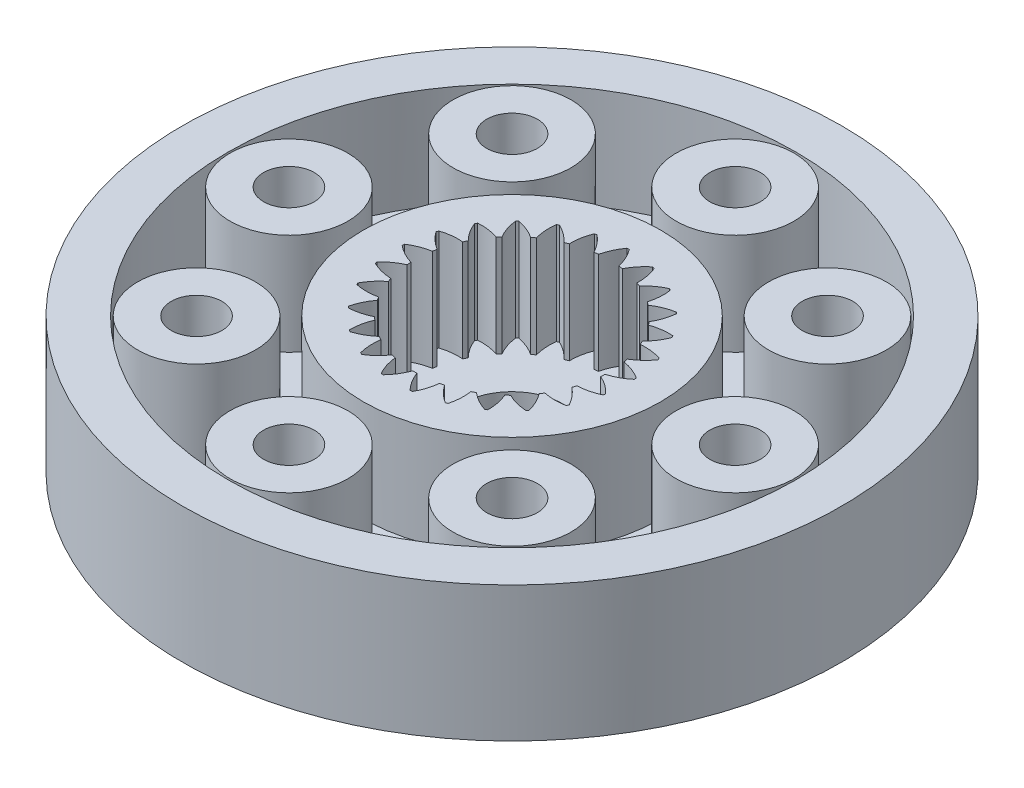
from build123d import *

# Parameters (mm, degrees)
SKETCH_1_R          = 9.75
EXTRUDE_1_DEPTH     = 3
SKETCH_2_R          = 9.75
EXTRUDE_2_DEPTH     = 1
SKETCH_4_R          = 1.5
CUT_EXTRUDE_4_DEPTH = 1
SKETCH_5_R          = 8.4
SKETCH_5_R_2        = 4.4
CUT_EXTRUDE_5_DEPTH = 10
SKETCH_6_R          = 1.744482362
SKETCH_6_R_2        = 0.75
EXTRUDE_3_DEPTH     = 3
SKETCH_7_R          = 0.75
SKETCH_7_R_2        = 1.5
CUT_EXTRUDE_6_DEPTH = 3


with BuildPart() as part:
    # 草图1 → 凸台-拉伸1 (new body)
    with BuildSketch(Plane(origin=(0, 0, 0), x_dir=(1, 0, 0), z_dir=(0, 1, 0))):
        with Locations((0.394660743, -0.591991115)):
            Circle(SKETCH_1_R)
        with BuildLine():
            ThreePointArc((-0.026116093, 2.25205035), (-0.201664975, 2.520045602), (-0.42818362, 2.746602811))
            ThreePointArc((-0.42818362, 2.746602811), (-0.460459434, 2.738482084), (-0.492655135, 2.73004934))
            ThreePointArc((-0.492655135, 2.73004934), (-0.582010169, 2.422389555), (-0.606737129, 2.102972206))
            ThreePointArc((-0.606737129, 2.102972206), (-0.663697346, 2.081116282), (-0.720180966, 2.058056613))
            ThreePointArc((-0.720180966, 2.058056613), (-0.956862366, 2.27397507), (-1.232606998, 2.437081672))
            ThreePointArc((-1.232606998, 2.437081672), (-1.261849265, 2.421189404), (-1.290936341, 2.405014844))
            ThreePointArc((-1.290936341, 2.405014844), (-1.300972245, 2.084799064), (-1.245486498, 1.769267453))
            ThreePointArc((-1.245486498, 1.769267453), (-1.295221857, 1.733932744), (-1.344196234, 1.697550632))
            ThreePointArc((-1.344196234, 1.697550632), (-1.62713859, 1.847825343), (-1.934783159, 1.937232749))
            ThreePointArc((-1.934783159, 1.937232749), (-1.95915448, 1.91456751), (-1.983305283, 1.891667442))
            ThreePointArc((-1.983305283, 1.891667442), (-1.913391464, 1.579016002), (-1.781179383, 1.287196141))
            ThreePointArc((-1.781179383, 1.287196141), (-1.82056483, 1.240602855), (-1.858952723, 1.193184322))
            ThreePointArc((-1.858952723, 1.193184322), (-2.170377725, 1.268372974), (-2.490591793, 1.278463389))
            ThreePointArc((-2.490591793, 1.278463389), (-2.508560828, 1.250449319), (-2.526257873, 1.222262639))
            ThreePointArc((-2.526257873, 1.222262639), (-2.380787274, 0.936820578), (-2.180156231, 0.687048582))
            ThreePointArc((-2.180156231, 0.687048582), (-2.206717032, 0.632124348), (-2.23210639, 0.576648875))
            ThreePointArc((-2.23210639, 0.576648875), (-2.552446061, 0.572027088), (-2.865109398, 0.502166494))
            ThreePointArc((-2.865109398, 0.502166494), (-2.875547088, 0.47056382), (-2.885678405, 0.4388616))
            ThreePointArc((-2.885678405, 0.4388616), (-2.673791479, 0.198564293), (-2.417347859, 0.006534255))
            ThreePointArc((-2.417347859, 0.006534255), (-2.429415102, -0.053269836), (-2.440210618, -0.113316522))
            ThreePointArc((-2.440210618, -0.113316522), (-2.749336837, -0.197458343), (-3.034803657, -0.342880348))
            ThreePointArc((-3.034803657, -0.342880348), (-3.037054162, -0.376085914), (-3.038983164, -0.409311707))
            ThreePointArc((-3.038983164, -0.409311707), (-2.773993545, -0.589365496), (-2.477850645, -0.711587622))
            ThreePointArc((-2.477850645, -0.711587622), (-2.474666101, -0.772513859), (-2.470189451, -0.833358803))
            ThreePointArc((-2.470189451, -0.833358803), (-2.748678682, -0.991733719), (-2.989012055, -1.203579736))
            ThreePointArc((-2.989012055, -1.203579736), (-2.982933968, -1.236301765), (-2.976539448, -1.268963432))
            ThreePointArc((-2.976539448, -1.268963432), (-2.675097409, -1.377460262), (-2.357862976, -1.422194811))
            ThreePointArc((-2.357862976, -1.422194811), (-2.339626741, -1.480414974), (-2.320159211, -1.538235065))
            ThreePointArc((-2.320159211, -1.538235065), (-2.550512951, -1.760891797), (-2.730611847, -2.025850761))
            ThreePointArc((-2.730611847, -2.025850761), (-2.716587076, -2.056033209), (-2.702270826, -2.086078497))
            ThreePointArc((-2.702270826, -2.086078497), (-2.383317078, -2.116201113), (-2.064924118, -2.080637248))
            ThreePointArc((-2.064924118, -2.080637248), (-2.032782042, -2.132493151), (-1.999546849, -2.18365534))
            ThreePointArc((-1.999546849, -2.18365534), (-2.167291125, -2.456603546), (-2.275839268, -2.758027112))
            ThreePointArc((-2.275839268, -2.758027112), (-2.254749042, -2.783773504), (-2.233410603, -2.809314557))
            ThreePointArc((-2.233410603, -2.809314557), (-1.916986184, -2.759170244), (-1.617440498, -2.645542574))
            ThreePointArc((-1.617440498, -2.645542574), (-1.573412186, -2.687775919), (-1.528497619, -2.729065497))
            ThreePointArc((-1.528497619, -2.729065497), (-1.623092441, -3.035154839), (-1.653269352, -3.354103454))
            ThreePointArc((-1.653269352, -3.354103454), (-1.626438847, -3.37379605), (-1.599418993, -3.393228031))
            ThreePointArc((-1.599418993, -3.393228031), (-1.305406012, -3.26596754), (-1.043529157, -3.081415709))
            ThreePointArc((-1.043529157, -3.081415709), (-0.99038107, -3.11137282), (-0.936609275, -3.140195412))
            ThreePointArc((-0.936609275, -3.140195412), (-0.952110903, -3.460193169), (-0.902020456, -3.77662612))
            ThreePointArc((-0.902020456, -3.77662612), (-0.871135531, -3.789027562), (-0.840132018, -3.801129486))
            ThreePointArc((-0.840132018, -3.801129486), (-0.587004393, -3.604749063), (-0.379251055, -3.360869142))
            ThreePointArc((-0.379251055, -3.360869142), (-0.320322682, -3.376667703), (-0.261072341, -3.391212279))
            ThreePointArc((-0.261072341, -3.391212279), (-0.19650675, -3.705011816), (-0.069296312, -3.999046457))
            ThreePointArc((-0.069296312, -3.999046457), (-0.03629758, -4.003377516), (-0.003258474, -4.007388976))
            ThreePointArc((-0.003258474, -4.007388976), (0.193078856, -3.754227924), (0.333654771, -3.466343785))
            ThreePointArc((0.333654771, -3.466343785), (0.394660743, -3.466991115), (0.455666715, -3.466343785))
            ThreePointArc((0.455666715, -3.466343785), (0.596242631, -3.754227924), (0.792579961, -4.007388976))
            ThreePointArc((0.792579961, -4.007388976), (0.825619067, -4.003377516), (0.858617799, -3.999046457))
            ThreePointArc((0.858617799, -3.999046457), (0.985828237, -3.705011816), (1.050393827, -3.391212279))
            ThreePointArc((1.050393827, -3.391212279), (1.109644169, -3.376667703), (1.168572542, -3.360869142))
            ThreePointArc((1.168572542, -3.360869142), (1.37632588, -3.604749063), (1.629453505, -3.801129486))
            ThreePointArc((1.629453505, -3.801129486), (1.660457018, -3.789027562), (1.691341943, -3.77662612))
            ThreePointArc((1.691341943, -3.77662612), (1.74143239, -3.460193169), (1.725930762, -3.140195412))
            ThreePointArc((1.725930762, -3.140195412), (1.779702556, -3.11137282), (1.832850644, -3.081415709))
            ThreePointArc((1.832850644, -3.081415709), (2.094727499, -3.26596754), (2.388740479, -3.393228031))
            ThreePointArc((2.388740479, -3.393228031), (2.415760333, -3.37379605), (2.442590839, -3.354103454))
            ThreePointArc((2.442590839, -3.354103454), (2.412413927, -3.035154839), (2.317819105, -2.729065497))
            ThreePointArc((2.317819105, -2.729065497), (2.362733673, -2.687775919), (2.406761985, -2.645542574))
            ThreePointArc((2.406761985, -2.645542574), (2.706307671, -2.759170244), (3.02273209, -2.809314557))
            ThreePointArc((3.02273209, -2.809314557), (3.044070529, -2.783773504), (3.065160755, -2.758027112))
            ThreePointArc((3.065160755, -2.758027112), (2.956612612, -2.456603546), (2.788868336, -2.18365534))
            ThreePointArc((2.788868336, -2.18365534), (2.822103529, -2.132493151), (2.854245605, -2.080637248))
            ThreePointArc((2.854245605, -2.080637248), (3.172638565, -2.116201113), (3.491592313, -2.086078497))
            ThreePointArc((3.491592313, -2.086078497), (3.505908563, -2.056033209), (3.519933334, -2.025850761))
            ThreePointArc((3.519933334, -2.025850761), (3.339834438, -1.760891797), (3.109480698, -1.538235065))
            ThreePointArc((3.109480698, -1.538235065), (3.128948228, -1.480414974), (3.147184462, -1.422194811))
            ThreePointArc((3.147184462, -1.422194811), (3.464418895, -1.377460262), (3.765860935, -1.268963432))
            ThreePointArc((3.765860935, -1.268963432), (3.772255455, -1.236301765), (3.778333542, -1.203579736))
            ThreePointArc((3.778333542, -1.203579736), (3.538000169, -0.991733719), (3.259510938, -0.833358803))
            ThreePointArc((3.259510938, -0.833358803), (3.263987588, -0.772513859), (3.267172132, -0.711587622))
            ThreePointArc((3.267172132, -0.711587622), (3.563315032, -0.589365496), (3.828304651, -0.409311707))
            ThreePointArc((3.828304651, -0.409311707), (3.826375649, -0.376085914), (3.824125144, -0.342880348))
            ThreePointArc((3.824125144, -0.342880348), (3.538658323, -0.197458343), (3.229532104, -0.113316522))
            ThreePointArc((3.229532104, -0.113316522), (3.218736589, -0.053269836), (3.206669346, 0.006534255))
            ThreePointArc((3.206669346, 0.006534255), (3.463112965, 0.198564293), (3.674999892, 0.4388616))
            ThreePointArc((3.674999892, 0.4388616), (3.664868575, 0.47056382), (3.654430885, 0.502166494))
            ThreePointArc((3.654430885, 0.502166494), (3.341767547, 0.572027088), (3.021427877, 0.576648875))
            ThreePointArc((3.021427877, 0.576648875), (2.996038519, 0.632124348), (2.969477718, 0.687048582))
            ThreePointArc((2.969477718, 0.687048582), (3.170108761, 0.936820578), (3.31557936, 1.222262639))
            ThreePointArc((3.31557936, 1.222262639), (3.297882315, 1.250449319), (3.279913279, 1.278463389))
            ThreePointArc((3.279913279, 1.278463389), (2.959699212, 1.268372974), (2.64827421, 1.193184322))
            ThreePointArc((2.64827421, 1.193184322), (2.609886316, 1.240602855), (2.57050087, 1.287196141))
            ThreePointArc((2.57050087, 1.287196141), (2.702712951, 1.579016002), (2.772626769, 1.891667442))
            ThreePointArc((2.772626769, 1.891667442), (2.748475967, 1.91456751), (2.724104646, 1.937232749))
            ThreePointArc((2.724104646, 1.937232749), (2.416460076, 1.847825343), (2.133517721, 1.697550632))
            ThreePointArc((2.133517721, 1.697550632), (2.084543344, 1.733932744), (2.034807985, 1.769267453))
            ThreePointArc((2.034807985, 1.769267453), (2.090293731, 2.084799064), (2.080257828, 2.405014844))
            ThreePointArc((2.080257828, 2.405014844), (2.051170752, 2.421189404), (2.021928485, 2.437081672))
            ThreePointArc((2.021928485, 2.437081672), (1.746183853, 2.27397507), (1.509502453, 2.058056613))
            ThreePointArc((1.509502453, 2.058056613), (1.453018832, 2.081116282), (1.396058616, 2.102972206))
            ThreePointArc((1.396058616, 2.102972206), (1.371331655, 2.422389555), (1.281976622, 2.73004934))
            ThreePointArc((1.281976622, 2.73004934), (1.24978092, 2.738482084), (1.217505107, 2.746602811))
            ThreePointArc((1.217505107, 2.746602811), (0.990986462, 2.520045602), (0.81543758, 2.25205035))
            ThreePointArc((0.81543758, 2.25205035), (0.75499379, 2.260338651), (0.694387736, 2.267342501))
            ThreePointArc((0.694387736, 2.267342501), (0.591001754, 2.570575422), (0.427942096, 2.846347815))
            ThreePointArc((0.427942096, 2.846347815), (0.394660743, 2.846508885), (0.361379391, 2.846347815))
            ThreePointArc((0.361379391, 2.846347815), (0.198319733, 2.570575422), (0.094933751, 2.267342501))
            ThreePointArc((0.094933751, 2.267342501), (0.034327697, 2.260338651), (-0.026116093, 2.25205035))
        make_face(mode=Mode.SUBTRACT)
    extrude(amount=EXTRUDE_1_DEPTH)

    # 草图2 → 凸台-拉伸2 (add)
    with BuildSketch(Plane(origin=(0, 0, 0), x_dir=(-1, 0, 0), z_dir=(0, -1, 0))):
        with Locations((-0.394660743, -0.591991115)):
            Circle(SKETCH_2_R)
    extrude(amount=EXTRUDE_2_DEPTH)

    # 草图4 → 切除-拉伸4 (cut)
    with BuildSketch(Plane(origin=(0, 0, 0), x_dir=(1, 0, 0), z_dir=(0, 1, 0))):
        with Locations((0.394660743, -0.591991115)):
            Circle(SKETCH_4_R)
    extrude(amount=-CUT_EXTRUDE_4_DEPTH, mode=Mode.SUBTRACT)

    # 草图5 → 切除-拉伸5 (cut)
    with BuildSketch(Plane(origin=(0, 0, 0), x_dir=(-1, 0, 0), z_dir=(0, -1, 0))):
        with Locations((-0.394660743, -0.591991115)):
            Circle(SKETCH_5_R)
        with Locations((-0.394660743, -0.591991115)):
            Circle(SKETCH_5_R_2, mode=Mode.SUBTRACT)
    extrude(amount=-CUT_EXTRUDE_5_DEPTH, mode=Mode.SUBTRACT)

    # 草图6 → 凸台-拉伸3 (add)
    with BuildSketch(Plane(origin=(0, 0, 0), x_dir=(-1, 0, 0), z_dir=(0, -1, 0))):
        with Locations((-0.394660743, 6.008008885)):
            Circle(SKETCH_6_R)
        with Locations((-0.394660743, 6.008008885)):
            Circle(SKETCH_6_R_2, mode=Mode.SUBTRACT)
        with Locations((4.272244012, 4.074913641)):
            Circle(SKETCH_6_R)
        with Locations((4.272244012, 4.074913641)):
            Circle(SKETCH_6_R_2, mode=Mode.SUBTRACT)
        with Locations((6.205339257, -0.591991115)):
            Circle(SKETCH_6_R)
        with Locations((6.205339257, -0.591991115)):
            Circle(SKETCH_6_R_2, mode=Mode.SUBTRACT)
        with Locations((4.272244012, -5.258895871)):
            Circle(SKETCH_6_R)
        with Locations((4.272244012, -5.258895871)):
            Circle(SKETCH_6_R_2, mode=Mode.SUBTRACT)
        with Locations((-0.394660743, -7.191991115)):
            Circle(SKETCH_6_R)
        with Locations((-0.394660743, -7.191991115)):
            Circle(SKETCH_6_R_2, mode=Mode.SUBTRACT)
        with Locations((-5.061565499, -5.258895871)):
            Circle(SKETCH_6_R)
        with Locations((-5.061565499, -5.258895871)):
            Circle(SKETCH_6_R_2, mode=Mode.SUBTRACT)
        with Locations((-6.994660743, -0.591991115)):
            Circle(SKETCH_6_R)
        with Locations((-6.994660743, -0.591991115)):
            Circle(SKETCH_6_R_2, mode=Mode.SUBTRACT)
        with Locations((-5.061565499, 4.074913641)):
            Circle(SKETCH_6_R)
        with Locations((-5.061565499, 4.074913641)):
            Circle(SKETCH_6_R_2, mode=Mode.SUBTRACT)
    extrude(amount=-EXTRUDE_3_DEPTH)

    # 草图7 → 切除-拉伸6 (cut)
    with BuildSketch(Plane(origin=(0, -1, 0), x_dir=(-1, 0, 0), z_dir=(0, -1, 0))):
        with Locations((-0.394660743, 6.008008885)):
            Circle(SKETCH_7_R)
        with Locations((-0.394660743, -0.591991115)):
            Circle(SKETCH_7_R_2)
        with Locations((4.272244012, 4.074913641)):
            Circle(SKETCH_7_R)
        with Locations((6.205339257, -0.591991115)):
            Circle(SKETCH_7_R)
        with Locations((4.272244012, -5.258895871)):
            Circle(SKETCH_7_R)
        with Locations((-0.394660743, -7.191991115)):
            Circle(SKETCH_7_R)
        with Locations((-5.061565499, -5.258895871)):
            Circle(SKETCH_7_R)
        with Locations((-6.994660743, -0.591991115)):
            Circle(SKETCH_7_R)
        with Locations((-5.061565499, 4.074913641)):
            Circle(SKETCH_7_R)
    extrude(amount=-CUT_EXTRUDE_6_DEPTH, mode=Mode.SUBTRACT)


solid = part.part
